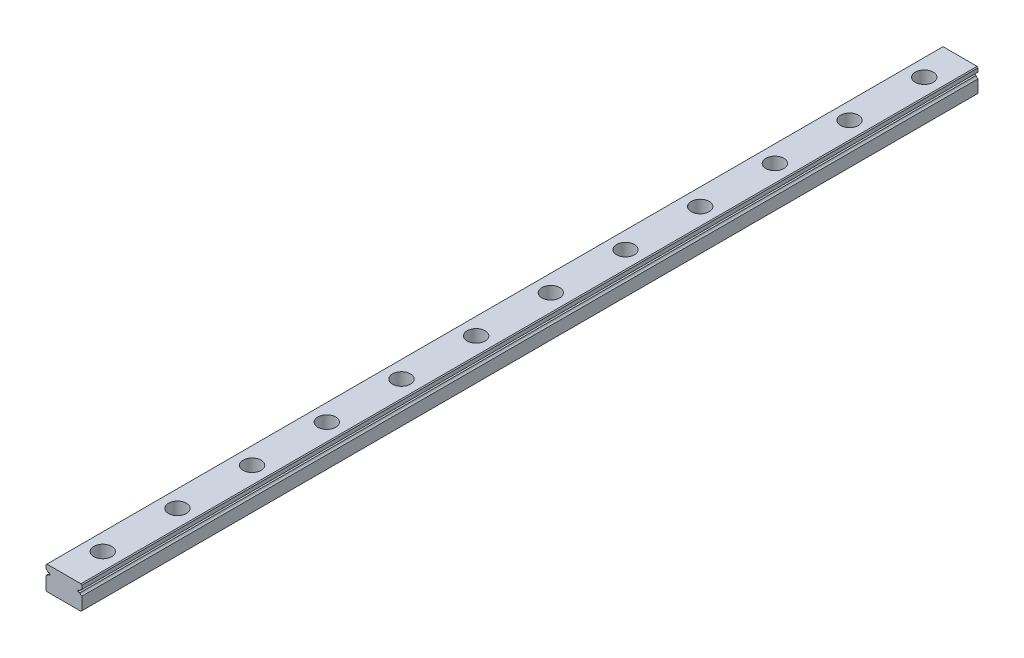
from build123d import *

# Parameters (mm, degrees)
EXTRUDE_1_DEPTH        = 300
SKETCH_2_R             = 3
SKETCH_2_R_2           = 1.75
CUT_EXTRUDE_1_DEPTH    = 4.5
SKETCH_2_2_R           = 1.75
CUT_EXTRUDE_2_DEPTH    = 9
PATTERN_LINEAR_1_COUNT = 16
PATTERN_LINEAR_1_PITCH = 25


with BuildPart() as part:
    # Эскиз1 → Бобышка-Вытянуть1 (new body)
    with BuildSketch(Plane.XY):
        with BuildLine():
            Line((-6, 3.7), (-5.7, 4))
            Line((-5.7, 4), (5.7, 4))
            Line((5.7, 4), (6, 3.7))
            Line((6, 3.7), (6, 2.451013544))
            ThreePointArc((6, 2.451013544), (5.597935912, 2.202976267), (5.354599002, 1.798050138))
            Line((5.354599002, 1.798050138), (4.643514056, 1.798050138))
            Line((4.643514056, 1.798050138), (4.643514056, 1.201949862))
            Line((4.643514056, 1.201949862), (5.354599002, 1.201949862))
            ThreePointArc((5.354599002, 1.201949862), (5.597935912, 0.797023733), (6, 0.548986456))
            Line((6, 0.548986456), (6, -3.7))
            Line((6, -3.7), (5.7, -4))
            Line((5.7, -4), (-5.7, -4))
            Line((-5.7, -4), (-6, -3.7))
            Line((-6, -3.7), (-6, 0.548986456))
            ThreePointArc((-6, 0.548986456), (-5.597935912, 0.797023733), (-5.354599002, 1.201949862))
            Line((-5.354599002, 1.201949862), (-4.643514056, 1.201949862))
            Line((-4.643514056, 1.201949862), (-4.643514056, 1.798050138))
            Line((-4.643514056, 1.798050138), (-5.354599002, 1.798050138))
            ThreePointArc((-5.354599002, 1.798050138), (-5.597935912, 2.202976267), (-6, 2.451013544))
            Line((-6, 2.451013544), (-6, 3.7))
        make_face()
    extrude(amount=EXTRUDE_1_DEPTH)

    # Эскиз2 → Вырез-Вытянуть1 (cut)
    with BuildSketch(Plane(origin=(0, 4, 0), x_dir=(1, 0, 0), z_dir=(0, 1, 0))):
        with Locations((0, -12)):
            Circle(SKETCH_2_R)
        with Locations((0, -12)):
            Circle(SKETCH_2_R_2, mode=Mode.SUBTRACT)
    cut_extrude_1 = extrude(amount=-CUT_EXTRUDE_1_DEPTH, mode=Mode.SUBTRACT)

    # Эскиз2<2> → Вырез-Вытянуть2 (cut, through all)
    with BuildSketch(Plane(origin=(0, 4, 0), x_dir=(1, 0, 0), z_dir=(0, 1, 0))):
        with Locations((0, -12)):
            Circle(SKETCH_2_2_R)
    cut_extrude_2 = extrude(amount=-CUT_EXTRUDE_2_DEPTH, mode=Mode.SUBTRACT)

    # Линейный массив1: Вырез-Вытянуть1, Вырез-Вытянуть2 ×16
    with Locations(*[(0, 0, i * PATTERN_LINEAR_1_PITCH) for i in range(1, PATTERN_LINEAR_1_COUNT)]):
        add(cut_extrude_1, mode=Mode.SUBTRACT)
        add(cut_extrude_2, mode=Mode.SUBTRACT)


solid = part.part
